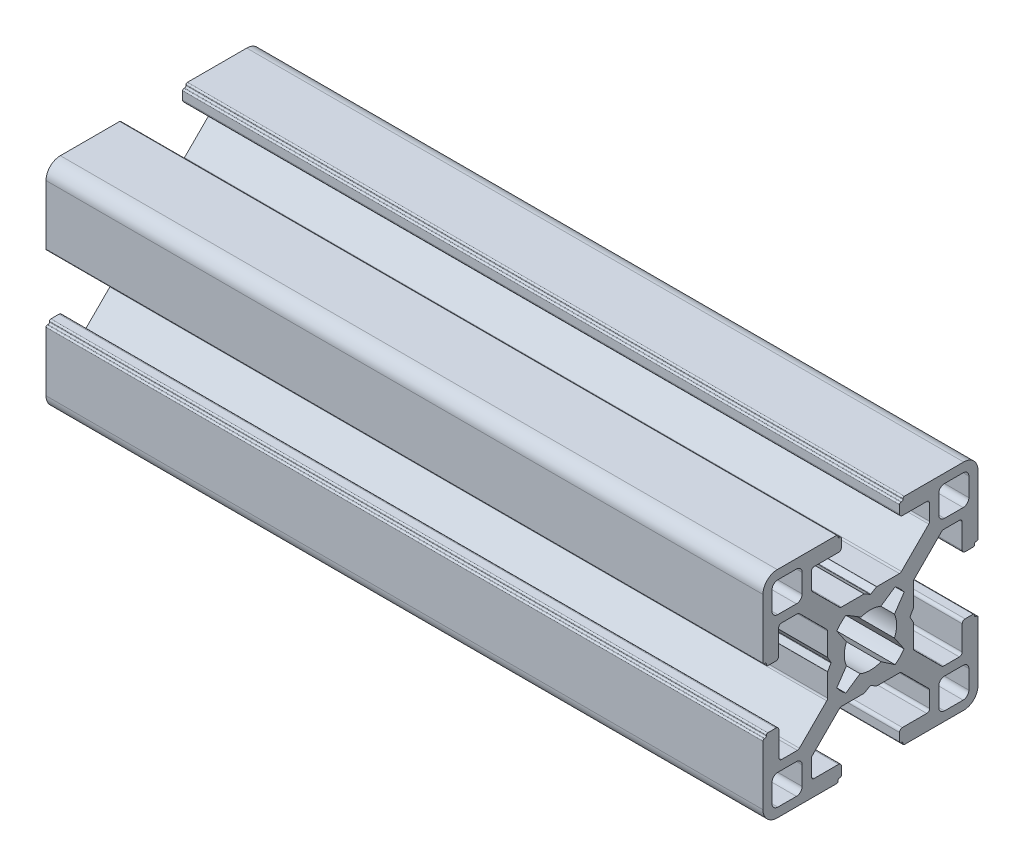
from build123d import *

# Parameters (mm, degrees)
BOSS_EXTRUDE2_DEPTH = 100


with BuildPart() as part:
    # Sketch2 → Boss-Extrude2 (new body)
    with BuildSketch(Plane(origin=(0, 0, 0), x_dir=(0, 0, -1), z_dir=(1, 0, 0))):
        with BuildLine():
            Line((0.032392183, 5.517163242), (0.825212506, 5.974898269))
            ThreePointArc((0.825212506, 5.974898269), (0.849330602, 5.984888311), (0.875212506, 5.988295728))
            Line((0.875212506, 5.988295728), (4.020655534, 5.988295728))
            ThreePointArc((4.020655534, 5.988295728), (4.173728907, 6.018743915), (4.303498246, 6.105453016))
            Line((4.303498246, 6.105453016), (8.115234896, 9.917189665))
            ThreePointArc((8.115234896, 9.917189665), (8.201943996, 10.046959004), (8.232392183, 10.200032377))
            Line((8.232392183, 10.200032377), (8.232392183, 12.388295728))
            ThreePointArc((8.232392183, 12.388295728), (8.115234896, 12.671138441), (7.832392183, 12.788295728))
            Line((7.832392183, 12.788295728), (4.432392183, 12.788295728))
            ThreePointArc((4.432392183, 12.788295728), (4.149549471, 12.905453016), (4.032392183, 13.188295728))
            Line((4.032392183, 13.188295728), (4.032392183, 14.308295728))
            ThreePointArc((4.032392183, 14.308295728), (4.090970827, 14.449717084), (4.232392183, 14.508295728))
            Line((4.232392183, 14.508295728), (4.312392183, 14.508295728))
            ThreePointArc((4.312392183, 14.508295728), (4.453813539, 14.566874372), (4.512392183, 14.708295728))
            Line((4.512392183, 14.708295728), (4.512392183, 14.788295728))
            ThreePointArc((4.512392183, 14.788295728), (4.570970827, 14.929717084), (4.712392183, 14.988295728))
            Line((4.712392183, 14.988295728), (12.982392183, 14.988295728))
            ThreePointArc((12.982392183, 14.988295728), (14.396605746, 14.402509291), (14.982392183, 12.988295728))
            Line((14.982392183, 12.988295728), (14.982392183, 4.718295728))
            ThreePointArc((14.982392183, 4.718295728), (14.923813539, 4.576874372), (14.782392183, 4.518295728))
            Line((14.782392183, 4.518295728), (14.702392183, 4.518295728))
            ThreePointArc((14.702392183, 4.518295728), (14.560970827, 4.459717084), (14.502392183, 4.318295728))
            Line((14.502392183, 4.318295728), (14.502392183, 4.238295728))
            ThreePointArc((14.502392183, 4.238295728), (14.443813539, 4.096874372), (14.302392183, 4.038295728))
            Line((14.302392183, 4.038295728), (13.182392183, 4.038295728))
            ThreePointArc((13.182392183, 4.038295728), (12.899549471, 4.155453016), (12.782392183, 4.438295728))
            Line((12.782392183, 4.438295728), (12.782392183, 7.838295728))
            ThreePointArc((12.782392183, 7.838295728), (12.665234896, 8.121138441), (12.382392183, 8.238295728))
            Line((12.382392183, 8.238295728), (10.194128832, 8.238295728))
            ThreePointArc((10.194128832, 8.238295728), (10.041055459, 8.207847541), (9.91128612, 8.121138441))
            Line((9.91128612, 8.121138441), (6.099549471, 4.309401791))
            ThreePointArc((6.099549471, 4.309401791), (6.01284037, 4.179632452), (5.982392183, 4.026559079))
            Line((5.982392183, 4.026559079), (5.982392183, 0.881116051))
            ThreePointArc((5.982392183, 0.881116051), (5.978984766, 0.855234147), (5.968994724, 0.831116051))
            Line((5.968994724, 0.831116051), (5.511259697, 0.038295728))
            ThreePointArc((5.511259697, 0.038295728), (5.497862237, -0.011704272), (5.511259697, -0.061704272))
            Line((5.511259697, -0.061704272), (5.968994724, -0.854524595))
            ThreePointArc((5.968994724, -0.854524595), (5.978984766, -0.87864269), (5.982392183, -0.904524595))
            Line((5.982392183, -0.904524595), (5.982392183, -4.049967623))
            ThreePointArc((5.982392183, -4.049967623), (6.01284037, -4.203040996), (6.099549471, -4.332810335))
            Line((6.099549471, -4.332810335), (9.91128612, -8.144546984))
            ThreePointArc((9.91128612, -8.144546984), (10.041055459, -8.231256085), (10.194128832, -8.261704272))
            Line((10.194128832, -8.261704272), (12.382392183, -8.261704272))
            ThreePointArc((12.382392183, -8.261704272), (12.665234896, -8.144546984), (12.782392183, -7.861704272))
            Line((12.782392183, -7.861704272), (12.782392183, -4.461704272))
            ThreePointArc((12.782392183, -4.461704272), (12.899549471, -4.178861559), (13.182392183, -4.061704272))
            Line((13.182392183, -4.061704272), (14.302392183, -4.061704272))
            ThreePointArc((14.302392183, -4.061704272), (14.443813539, -4.120282916), (14.502392183, -4.261704272))
            Line((14.502392183, -4.261704272), (14.502392183, -4.341704272))
            ThreePointArc((14.502392183, -4.341704272), (14.560970827, -4.483125628), (14.702392183, -4.541704272))
            Line((14.702392183, -4.541704272), (14.782392183, -4.541704272))
            ThreePointArc((14.782392183, -4.541704272), (14.923813539, -4.600282916), (14.982392183, -4.741704272))
            Line((14.982392183, -4.741704272), (14.982392183, -13.011704272))
            ThreePointArc((14.982392183, -13.011704272), (14.396605746, -14.425917834), (12.982392183, -15.011704272))
            Line((12.982392183, -15.011704272), (4.712392183, -15.011704272))
            ThreePointArc((4.712392183, -15.011704272), (4.570970827, -14.953125628), (4.512392183, -14.811704272))
            Line((4.512392183, -14.811704272), (4.512392183, -14.731704272))
            ThreePointArc((4.512392183, -14.731704272), (4.453813539, -14.590282916), (4.312392183, -14.531704272))
            Line((4.312392183, -14.531704272), (4.232392183, -14.531704272))
            ThreePointArc((4.232392183, -14.531704272), (4.090970827, -14.473125628), (4.032392183, -14.331704272))
            Line((4.032392183, -14.331704272), (4.032392183, -13.211704272))
            ThreePointArc((4.032392183, -13.211704272), (4.149549471, -12.928861559), (4.432392183, -12.811704272))
            Line((4.432392183, -12.811704272), (7.832392183, -12.811704272))
            ThreePointArc((7.832392183, -12.811704272), (8.115234896, -12.694546984), (8.232392183, -12.411704272))
            Line((8.232392183, -12.411704272), (8.232392183, -10.223440921))
            ThreePointArc((8.232392183, -10.223440921), (8.201943996, -10.070367548), (8.115234896, -9.940598209))
            Line((8.115234896, -9.940598209), (4.303498246, -6.128861559))
            ThreePointArc((4.303498246, -6.128861559), (4.173728907, -6.042152459), (4.020655534, -6.011704272))
            Line((4.020655534, -6.011704272), (0.875212506, -6.011704272))
            ThreePointArc((0.875212506, -6.011704272), (0.849330602, -6.008296854), (0.825212506, -5.998306812))
            Line((0.825212506, -5.998306812), (0.032392183, -5.540571785))
            ThreePointArc((0.032392183, -5.540571785), (-0.017607817, -5.527174326), (-0.067607817, -5.540571785))
            Line((-0.067607817, -5.540571785), (-0.86042814, -5.998306812))
            ThreePointArc((-0.86042814, -5.998306812), (-0.884546235, -6.008296854), (-0.91042814, -6.011704272))
            Line((-0.91042814, -6.011704272), (-4.055871168, -6.011704272))
            ThreePointArc((-4.055871168, -6.011704272), (-4.208944541, -6.042152459), (-4.33871388, -6.128861559))
            Line((-4.33871388, -6.128861559), (-8.150450529, -9.940598209))
            ThreePointArc((-8.150450529, -9.940598209), (-8.23715963, -10.070367548), (-8.267607817, -10.223440921))
            Line((-8.267607817, -10.223440921), (-8.267607817, -12.411704272))
            ThreePointArc((-8.267607817, -12.411704272), (-8.150450529, -12.694546984), (-7.867607817, -12.811704272))
            Line((-7.867607817, -12.811704272), (-4.467607817, -12.811704272))
            ThreePointArc((-4.467607817, -12.811704272), (-4.184765104, -12.928861559), (-4.067607817, -13.211704272))
            Line((-4.067607817, -13.211704272), (-4.067607817, -14.331704272))
            ThreePointArc((-4.067607817, -14.331704272), (-4.126186461, -14.473125628), (-4.267607817, -14.531704272))
            Line((-4.267607817, -14.531704272), (-4.347607817, -14.531704272))
            ThreePointArc((-4.347607817, -14.531704272), (-4.489029173, -14.590282916), (-4.547607817, -14.731704272))
            Line((-4.547607817, -14.731704272), (-4.547607817, -14.811704272))
            ThreePointArc((-4.547607817, -14.811704272), (-4.606186461, -14.953125628), (-4.747607817, -15.011704272))
            Line((-4.747607817, -15.011704272), (-13.017607817, -15.011704272))
            ThreePointArc((-13.017607817, -15.011704272), (-14.431821379, -14.425917834), (-15.017607817, -13.011704272))
            Line((-15.017607817, -13.011704272), (-15.017607817, -4.741704272))
            ThreePointArc((-15.017607817, -4.741704272), (-14.959029173, -4.600282916), (-14.817607817, -4.541704272))
            Line((-14.817607817, -4.541704272), (-14.737607817, -4.541704272))
            ThreePointArc((-14.737607817, -4.541704272), (-14.596186461, -4.483125628), (-14.537607817, -4.341704272))
            Line((-14.537607817, -4.341704272), (-14.537607817, -4.261704272))
            ThreePointArc((-14.537607817, -4.261704272), (-14.479029173, -4.120282916), (-14.337607817, -4.061704272))
            Line((-14.337607817, -4.061704272), (-13.2, -4.061704272))
            ThreePointArc((-13.2, -4.061704272), (-12.917157288, -4.178861559), (-12.8, -4.461704272))
            Line((-12.8, -4.461704272), (-12.8, -7.85))
            ThreePointArc((-12.8, -7.85), (-12.682842712, -8.132842712), (-12.4, -8.25))
            Line((-12.4, -8.25), (-10.211736649, -8.25))
            ThreePointArc((-10.211736649, -8.25), (-10.058663276, -8.219551813), (-9.928893937, -8.132842712))
            Line((-9.928893937, -8.132842712), (-6.117157288, -4.321106063))
            ThreePointArc((-6.117157288, -4.321106063), (-6.030448187, -4.191336724), (-6, -4.038263351))
            Line((-6, -4.038263351), (-6, -0.892820323))
            ThreePointArc((-6, -0.892820323), (-5.996592583, -0.866938419), (-5.98660254, -0.842820323))
            Line((-5.98660254, -0.842820323), (-5.528867513, -0.05))
            ThreePointArc((-5.528867513, -0.05), (-5.515470054, 0), (-5.528867513, 0.05))
            Line((-5.528867513, 0.05), (-5.98660254, 0.842820323))
            ThreePointArc((-5.98660254, 0.842820323), (-5.996592583, 0.866938419), (-6, 0.892820323))
            Line((-6, 0.892820323), (-6, 4.038263351))
            ThreePointArc((-6, 4.038263351), (-6.030448187, 4.191336724), (-6.117157288, 4.321106063))
            Line((-6.117157288, 4.321106063), (-9.928893937, 8.132842712))
            ThreePointArc((-9.928893937, 8.132842712), (-10.058663276, 8.219551813), (-10.211736649, 8.25))
            Line((-10.211736649, 8.25), (-12.417607817, 8.25))
            ThreePointArc((-12.417607817, 8.25), (-12.700450529, 8.132842712), (-12.817607817, 7.85))
            Line((-12.817607817, 7.85), (-12.817607817, 4.438295728))
            ThreePointArc((-12.817607817, 4.438295728), (-12.934765104, 4.155453016), (-13.217607817, 4.038295728))
            Line((-13.217607817, 4.038295728), (-14.337607817, 4.038295728))
            ThreePointArc((-14.337607817, 4.038295728), (-14.479029173, 4.096874372), (-14.537607817, 4.238295728))
            Line((-14.537607817, 4.238295728), (-14.537607817, 4.318295728))
            ThreePointArc((-14.537607817, 4.318295728), (-14.596186461, 4.459717084), (-14.737607817, 4.518295728))
            Line((-14.737607817, 4.518295728), (-14.817607817, 4.518295728))
            ThreePointArc((-14.817607817, 4.518295728), (-14.959029173, 4.576874372), (-15.017607817, 4.718295728))
            Line((-15.017607817, 4.718295728), (-15.017607817, 12.988295728))
            ThreePointArc((-15.017607817, 12.988295728), (-14.431821379, 14.402509291), (-13.017607817, 14.988295728))
            Line((-13.017607817, 14.988295728), (-4.747607817, 14.988295728))
            ThreePointArc((-4.747607817, 14.988295728), (-4.606186461, 14.929717084), (-4.547607817, 14.788295728))
            Line((-4.547607817, 14.788295728), (-4.547607817, 14.708295728))
            ThreePointArc((-4.547607817, 14.708295728), (-4.489029173, 14.566874372), (-4.347607817, 14.508295728))
            Line((-4.347607817, 14.508295728), (-4.267607817, 14.508295728))
            ThreePointArc((-4.267607817, 14.508295728), (-4.126186461, 14.449717084), (-4.067607817, 14.308295728))
            Line((-4.067607817, 14.308295728), (-4.067607817, 13.188295728))
            ThreePointArc((-4.067607817, 13.188295728), (-4.184765104, 12.905453016), (-4.467607817, 12.788295728))
            Line((-4.467607817, 12.788295728), (-7.867607817, 12.788295728))
            ThreePointArc((-7.867607817, 12.788295728), (-8.150450529, 12.671138441), (-8.267607817, 12.388295728))
            Line((-8.267607817, 12.388295728), (-8.267607817, 10.200032377))
            ThreePointArc((-8.267607817, 10.200032377), (-8.23715963, 10.046959004), (-8.150450529, 9.917189665))
            Line((-8.150450529, 9.917189665), (-4.33871388, 6.105453016))
            ThreePointArc((-4.33871388, 6.105453016), (-4.208944541, 6.018743915), (-4.055871168, 5.988295728))
            Line((-4.055871168, 5.988295728), (-0.91042814, 5.988295728))
            ThreePointArc((-0.91042814, 5.988295728), (-0.884546235, 5.984888311), (-0.86042814, 5.974898269))
            Line((-0.86042814, 5.974898269), (-0.067607817, 5.517163242))
            ThreePointArc((-0.067607817, 5.517163242), (-0.017607817, 5.503765782), (0.032392183, 5.517163242))
        make_face()
        with BuildLine():
            Line((10.310343956, 9.516247501), (12.910343956, 9.516247501))
            ThreePointArc((12.910343956, 9.516247501), (13.476029381, 9.750562076), (13.710343956, 10.316247501))
            Line((13.710343956, 10.316247501), (13.710343956, 12.916247501))
            ThreePointArc((13.710343956, 12.916247501), (13.476029381, 13.481932926), (12.910343956, 13.716247501))
            Line((12.910343956, 13.716247501), (10.310343956, 13.716247501))
            ThreePointArc((10.310343956, 13.716247501), (9.744658531, 13.481932926), (9.510343956, 12.916247501))
            Line((9.510343956, 12.916247501), (9.510343956, 10.316247501))
            ThreePointArc((9.510343956, 10.316247501), (9.744658531, 9.750562076), (10.310343956, 9.516247501))
        make_face(mode=Mode.SUBTRACT)
        with BuildLine():
            Line((-12.945559589, -13.739656044), (-10.345559589, -13.739656044))
            ThreePointArc((-10.345559589, -13.739656044), (-9.779874164, -13.505341469), (-9.545559589, -12.939656044))
            Line((-9.545559589, -12.939656044), (-9.545559589, -10.339656044))
            ThreePointArc((-9.545559589, -10.339656044), (-9.779874164, -9.773970619), (-10.345559589, -9.539656044))
            Line((-10.345559589, -9.539656044), (-12.945559589, -9.539656044))
            ThreePointArc((-12.945559589, -9.539656044), (-13.511245014, -9.773970619), (-13.745559589, -10.339656044))
            Line((-13.745559589, -10.339656044), (-13.745559589, -12.939656044))
            ThreePointArc((-13.745559589, -12.939656044), (-13.511245014, -13.505341469), (-12.945559589, -13.739656044))
        make_face(mode=Mode.SUBTRACT)
        with BuildLine():
            Line((-12.945559589, 13.716247501), (-10.345559589, 13.716247501))
            ThreePointArc((-10.345559589, 13.716247501), (-9.779874164, 13.481932926), (-9.545559589, 12.916247501))
            Line((-9.545559589, 12.916247501), (-9.545559589, 10.316247501))
            ThreePointArc((-9.545559589, 10.316247501), (-9.779874164, 9.750562076), (-10.345559589, 9.516247501))
            Line((-10.345559589, 9.516247501), (-12.945559589, 9.516247501))
            ThreePointArc((-12.945559589, 9.516247501), (-13.511245014, 9.750562076), (-13.745559589, 10.316247501))
            Line((-13.745559589, 10.316247501), (-13.745559589, 12.916247501))
            ThreePointArc((-13.745559589, 12.916247501), (-13.511245014, 13.481932926), (-12.945559589, 13.716247501))
        make_face(mode=Mode.SUBTRACT)
        with BuildLine():
            Line((10.310343956, -9.539656044), (12.910343956, -9.539656044))
            ThreePointArc((12.910343956, -9.539656044), (13.476029381, -9.773970619), (13.710343956, -10.339656044))
            Line((13.710343956, -10.339656044), (13.710343956, -12.939656044))
            ThreePointArc((13.710343956, -12.939656044), (13.476029381, -13.505341469), (12.910343956, -13.739656044))
            Line((12.910343956, -13.739656044), (10.310343956, -13.739656044))
            ThreePointArc((10.310343956, -13.739656044), (9.744658531, -13.505341469), (9.510343956, -12.939656044))
            Line((9.510343956, -12.939656044), (9.510343956, -10.339656044))
            ThreePointArc((9.510343956, -10.339656044), (9.744658531, -9.773970619), (10.310343956, -9.539656044))
        make_face(mode=Mode.SUBTRACT)
        with BuildLine():
            Line((-3.448409821, 4.691674688), (-1.309818494, 3.401899625))
            ThreePointArc((-1.309818494, 3.401899625), (0.06948364, 3.63725655), (1.435986861, 3.336364203))
            Line((1.435986861, 3.336364203), (3.418036349, 4.689685979))
            ThreePointArc((3.418036349, 4.689685979), (4.099838061, 4.105741606), (4.683782434, 3.423939894))
            Line((4.683782434, 3.423939894), (3.332604596, 1.436942264))
            ThreePointArc((3.332604596, 1.436942264), (3.632392183, -0.011704272), (3.332604596, -1.460350808))
            Line((3.332604596, -1.460350808), (4.682199666, -3.444939719))
            ThreePointArc((4.682199666, -3.444939719), (4.097929573, -4.127241662), (3.415627631, -4.711511755))
            Line((3.415627631, -4.711511755), (1.435986861, -3.359772747))
            ThreePointArc((1.435986861, -3.359772747), (-0.017607817, -3.661704272), (-1.471202495, -3.359772747))
            Line((-1.471202495, -3.359772747), (-3.453251982, -4.713094522))
            ThreePointArc((-3.453251982, -4.713094522), (-4.135053695, -4.12915015), (-4.718998067, -3.447348437))
            Line((-4.718998067, -3.447348437), (-3.36782023, -1.460350808))
            ThreePointArc((-3.36782023, -1.460350808), (-3.667607817, -0.011704272), (-3.36782023, 1.436942264))
            Line((-3.36782023, 1.436942264), (-4.720986777, 3.419097732))
            ThreePointArc((-4.720986777, 3.419097732), (-4.134170462, 4.104858374), (-3.448409821, 4.691674688))
        make_face(mode=Mode.SUBTRACT)
    extrude(amount=BOSS_EXTRUDE2_DEPTH)


solid = part.part
